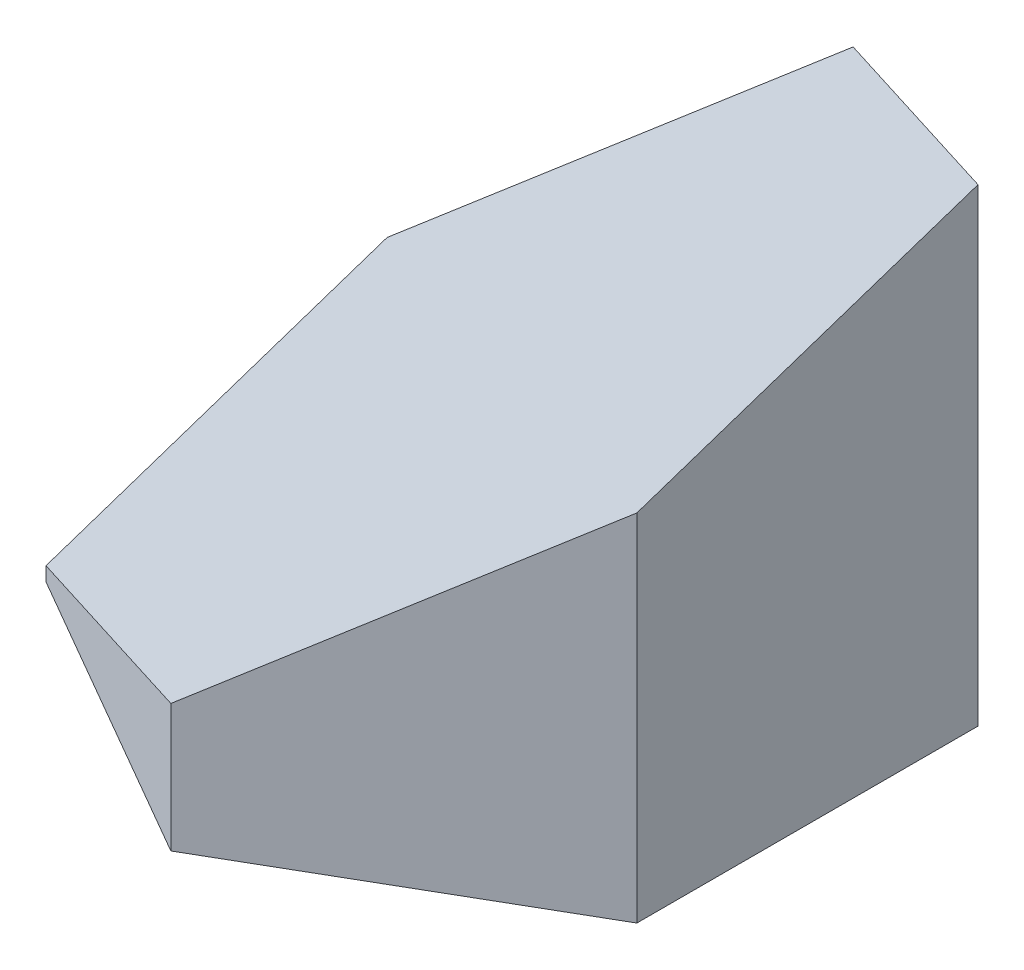
from build123d import *

# Parameters (mm, degrees)
BOSS_EXTRUDE1_DEPTH = 90


with BuildPart() as part:
    # Sketch1 → Boss-Extrude1 (new body)
    with BuildSketch(Plane(origin=(0, 0, 0), x_dir=(1, 0, 0), z_dir=(0, 1, 0))):
        Polygon((114.282032303, -73), (114.282032303, -33), (79.641016151, -13), (45, -33), (45, -73), (79.641016151, -93), align=None)
    extrude(amount=BOSS_EXTRUDE1_DEPTH)

    # SurfaceCut1
    split(bisect_by=Plane(origin=(0, 0, 0), x_dir=(-0.877058019, -0.455732715, -0.151910905), z_dir=(0.480384461, -0.832050294, -0.277350098)), keep=Keep.TOP)


solid = part.part
